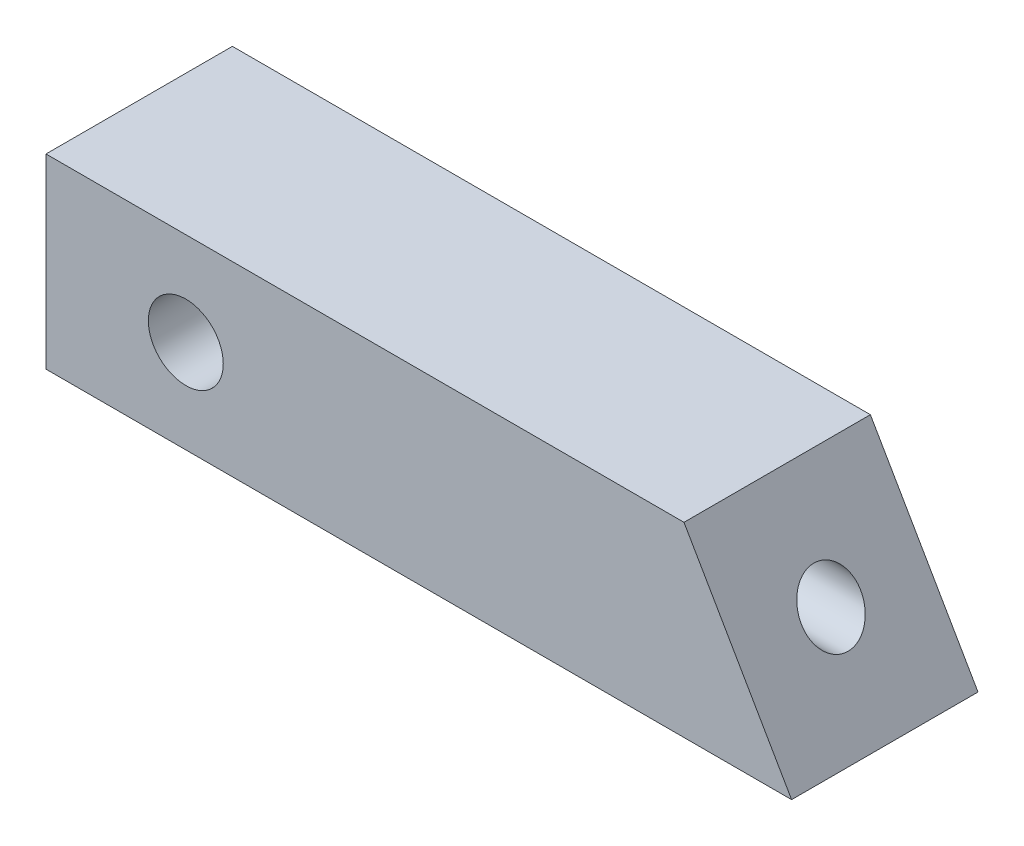
from build123d import *

# Parameters (mm, degrees)
SKETCH1_W                  = 12.7
SKETCH1_H                  = 12.7
BOSS_EXTRUDE1_DEPTH        = 50.8
F_10_32_TAPPED_HOLE1_D     = 4.0386
F_10_32_TAPPED_HOLE1_DEPTH = 25.4
F_10_32_TAPPED_HOLE1_TIP   = 1.213317848
CUT_EXTRUDE1_DEPTH         = 13.7
F_10_CLEARANCE_HOLE1_D     = 5.1054


with BuildPart() as part:
    # Sketch1 → Boss-Extrude1 (new body)
    with BuildSketch(Plane(origin=(0, 0, 0), x_dir=(0, 0, -1), z_dir=(1, 0, 0))):
        with Locations((6.35, 6.35)):
            Rectangle(SKETCH1_W, SKETCH1_H)
    extrude(amount=BOSS_EXTRUDE1_DEPTH)

    # #10-32 Tapped Hole1
    with Locations(Plane(origin=(50.8, 6.35, -6.35), x_dir=(0, 0, 1), z_dir=(1, 0, 0))):
        with Locations((0, 0)):
            Hole(F_10_32_TAPPED_HOLE1_D / 2, depth=F_10_32_TAPPED_HOLE1_DEPTH)
            with Locations((0, 0, -(F_10_32_TAPPED_HOLE1_DEPTH + F_10_32_TAPPED_HOLE1_TIP / 2))):  # 118° drill point
                Cone(0, F_10_32_TAPPED_HOLE1_D / 2, F_10_32_TAPPED_HOLE1_TIP, mode=Mode.SUBTRACT)

    # Sketch3 → Cut-Extrude1 (cut, through all)
    with BuildSketch(Plane.XY):
        Polygon((43.467651581, 12.7), (50.8, 0), (50.8, 12.7), align=None)
    extrude(amount=-CUT_EXTRUDE1_DEPTH, mode=Mode.SUBTRACT)

    # #10 Clearance Hole1 (through all)
    with Locations(Plane(origin=(9.525, 6.35, 0), x_dir=(1, 0, 0), z_dir=(0, 0, 1))):
        with Locations((0, 0)):
            Hole(F_10_CLEARANCE_HOLE1_D / 2)


solid = part.part
